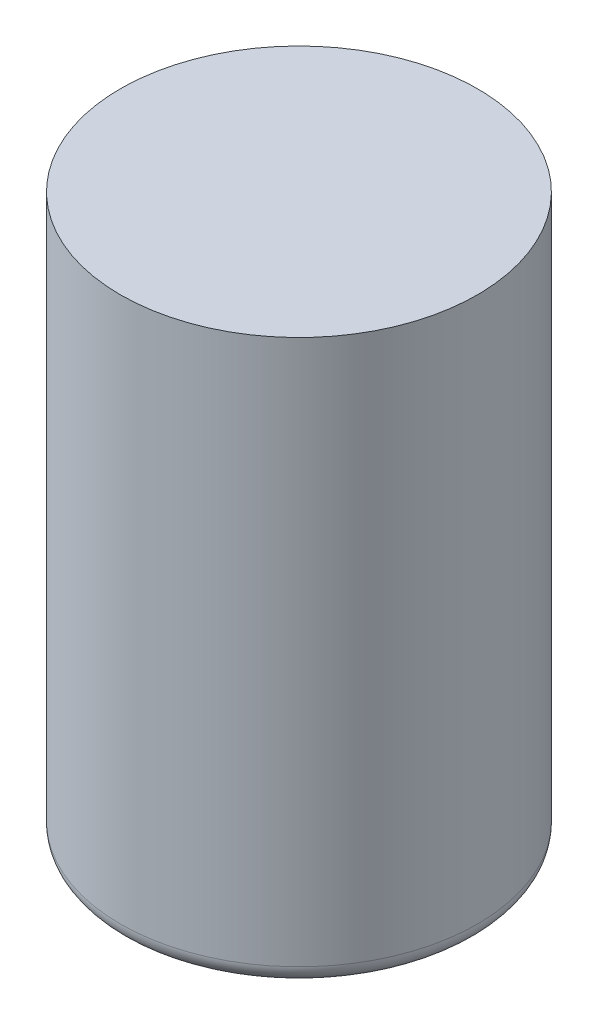
from build123d import *

# Parameters (mm, degrees)
ESQUISSE1_R        = 9.5
BOSS_EXTRU_1_DEPTH = 30
CONG_1_R           = 1
ECHELLE1_SCALE     = 10


with BuildPart() as part:
    # Esquisse1 → Boss.-Extru.1 (new body)
    with BuildSketch(Plane(origin=(0, 0, 0), x_dir=(1, 0, 0), z_dir=(0, 1, 0))):
        Circle(ESQUISSE1_R)
    extrude(amount=BOSS_EXTRU_1_DEPTH)

    # Congé1
    cong_1_edges = [part.edges().sort_by_distance(p)[0] for p in [
        (-9.5, 0, 0),
    ]]
    fillet(cong_1_edges, radius=CONG_1_R)


with BuildPart() as part_1:
    # Echelle1: scaled about (0, 0, 0)
    add(part.part.scale(ECHELLE1_SCALE))


solid = part_1.part
